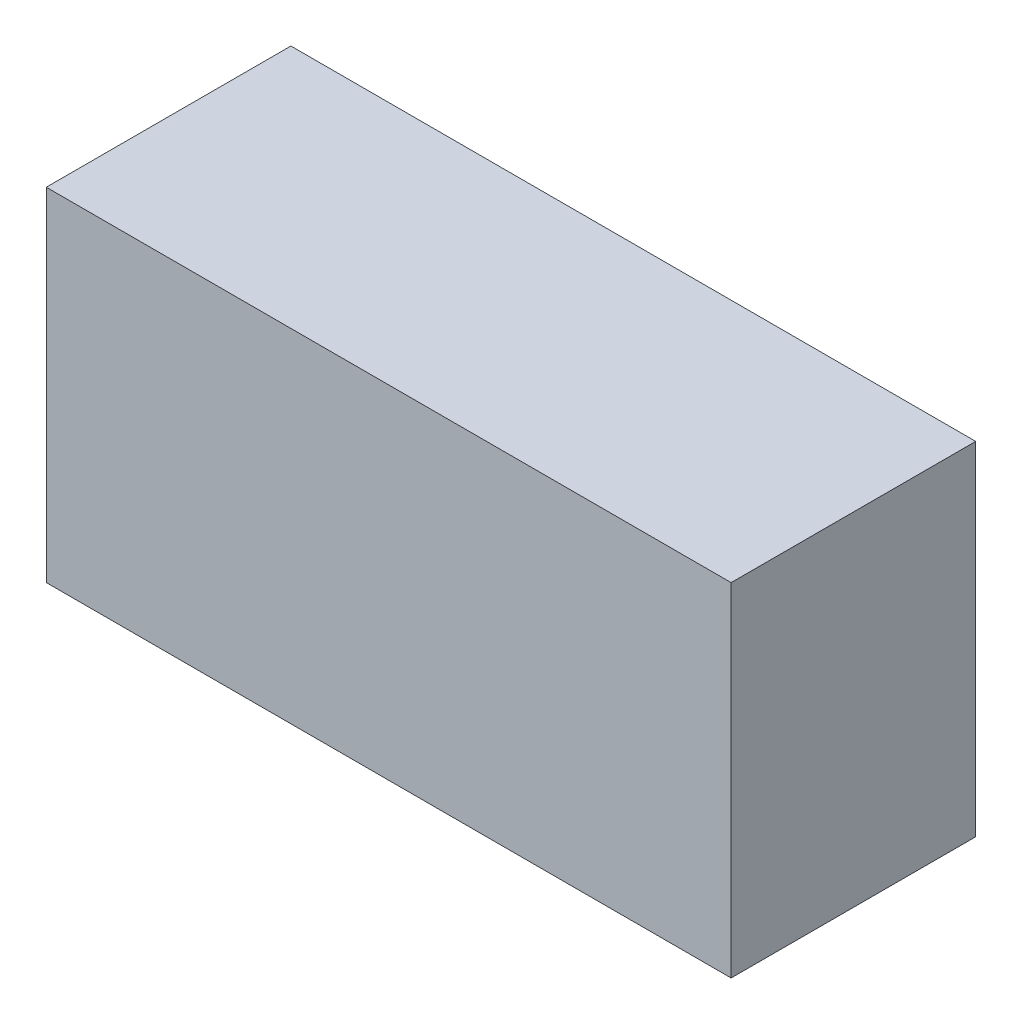
from build123d import *

# Parameters (mm, degrees)
ESQUISSE1_W        = 70
ESQUISSE1_H        = 35
BOSS_EXTRU_1_DEPTH = 25


with BuildPart() as part:
    # Esquisse1 → Boss.-Extru.1 (new body)
    with BuildSketch(Plane.XY):
        with Locations((35, 17.5)):
            Rectangle(ESQUISSE1_W, ESQUISSE1_H)
    extrude(amount=BOSS_EXTRU_1_DEPTH)


solid = part.part
